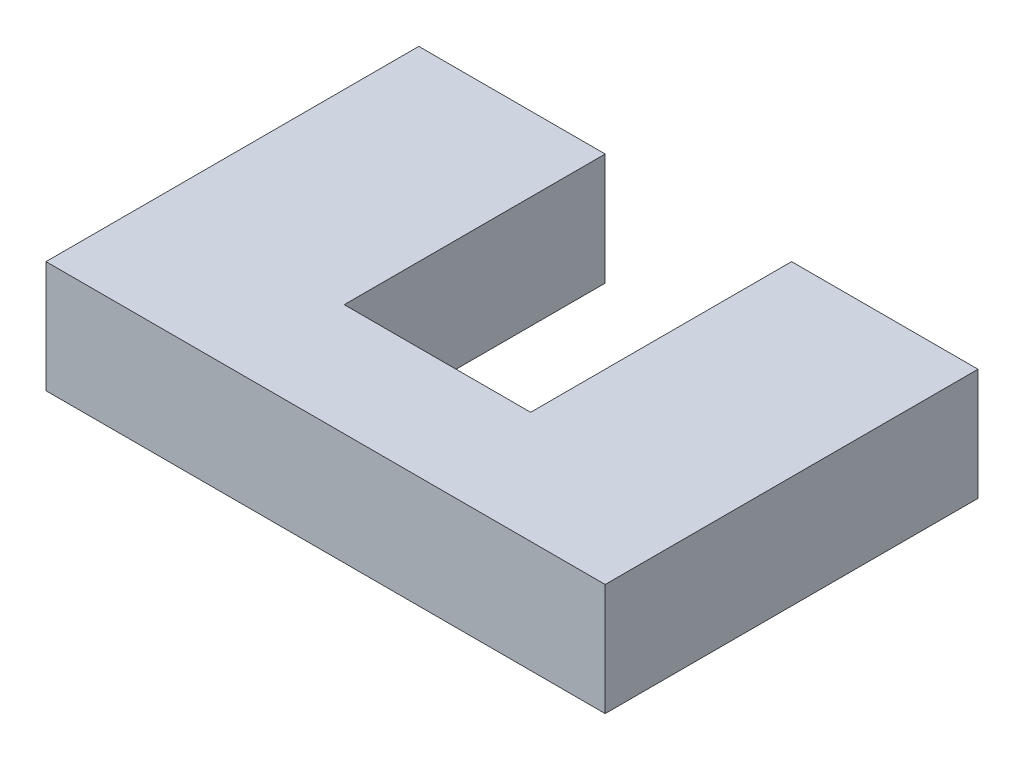
from build123d import *

# Parameters (mm, degrees)
SKETCH1_W           = 3
SKETCH1_H           = 2
BOSS_EXTRUDE1_DEPTH = 0.6
SKETCH2_W           = 1
SKETCH2_H           = 1.4
CUT_EXTRUDE1_DEPTH  = 0.6


with BuildPart() as part:
    # Sketch1 → Boss-Extrude1 (new body)
    with BuildSketch(Plane(origin=(0, 0, 0), x_dir=(1, 0, 0), z_dir=(0, 1, 0))):
        with Locations((1.5, -1)):
            Rectangle(SKETCH1_W, SKETCH1_H)
    extrude(amount=BOSS_EXTRUDE1_DEPTH)

    # Sketch2 → Cut-Extrude1 (cut)
    with BuildSketch(Plane(origin=(0, 0.6, 0), x_dir=(1, 0, 0), z_dir=(0, 1, 0))):
        with Locations((1.5, -0.7)):
            Rectangle(SKETCH2_W, SKETCH2_H)
    extrude(amount=-CUT_EXTRUDE1_DEPTH, mode=Mode.SUBTRACT)


solid = part.part
